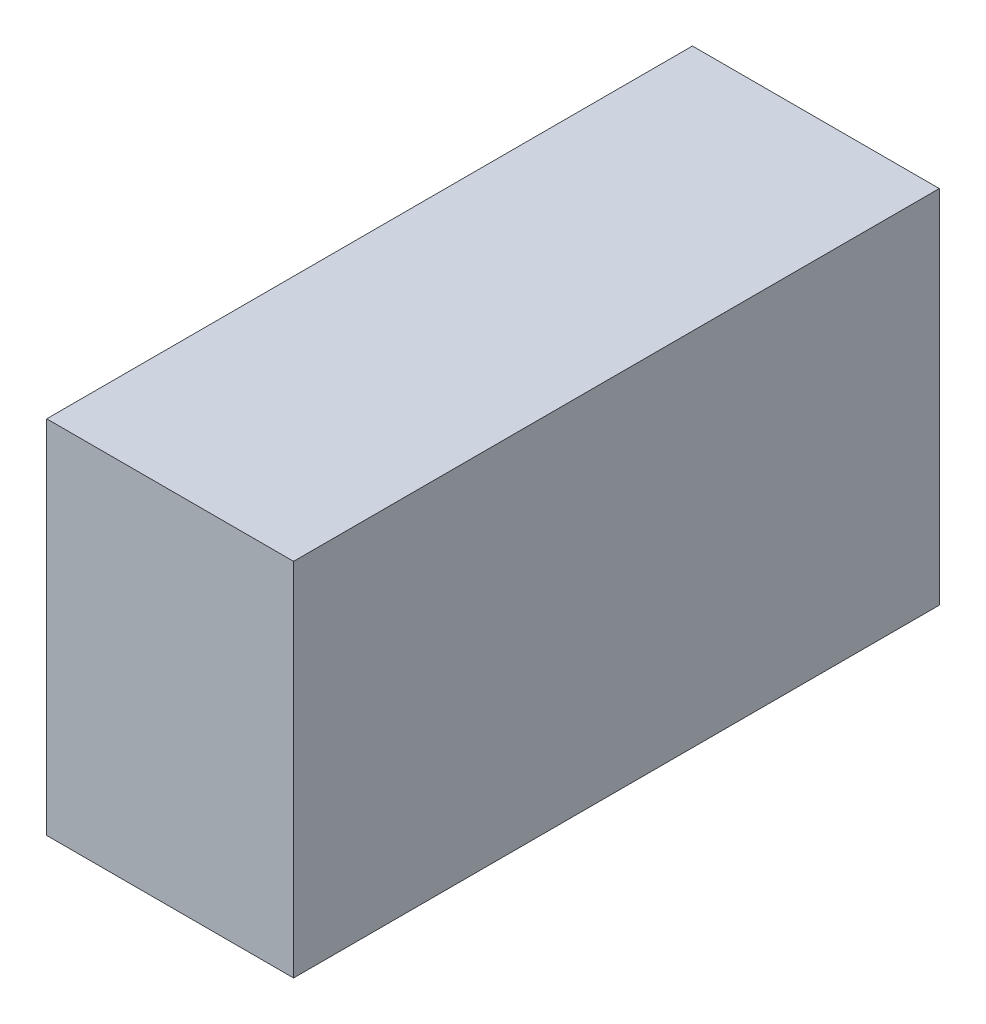
from build123d import *

# Parameters (mm, degrees)
SKETCH1_W           = 130
SKETCH1_H           = 340
BOSS_EXTRUDE1_DEPTH = 190


with BuildPart() as part:
    # Sketch1 → Boss-Extrude1 (new body)
    with BuildSketch(Plane(origin=(0, 0, 0), x_dir=(1, 0, 0), z_dir=(0, 1, 0))):
        Rectangle(SKETCH1_W, SKETCH1_H)
    extrude(amount=BOSS_EXTRUDE1_DEPTH)


solid = part.part
